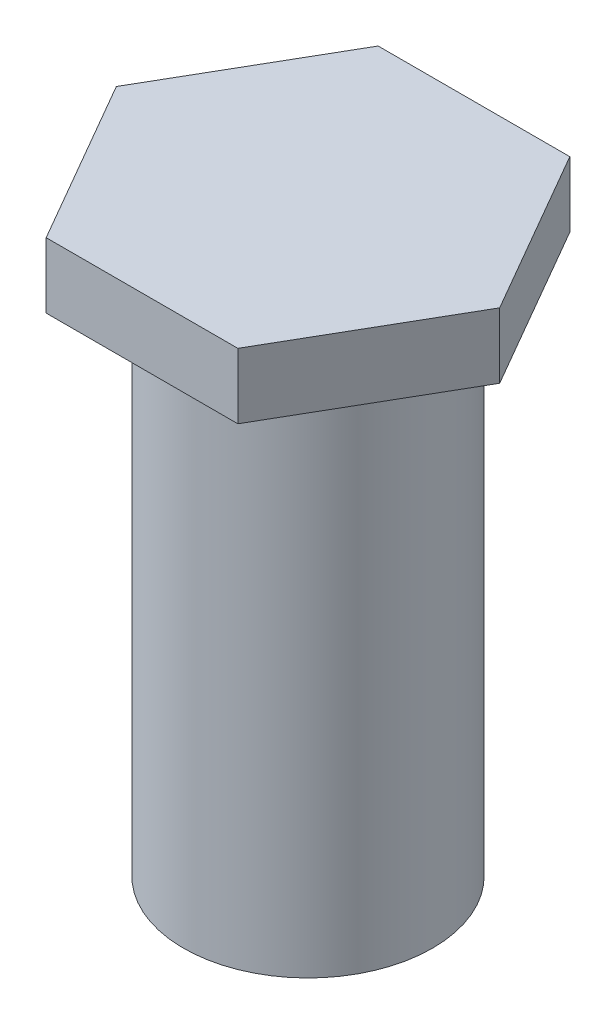
from build123d import *

# Parameters (mm, degrees)
CROQUIS1_W              = 4.765
CROQUIS1_H              = 20
SALIENTE_EXTRUIR1_DEPTH = 2.5


with BuildPart() as part:
    # Croquis1 → Revolución1 (revolve)
    with BuildSketch(Plane.XY):
        with Locations((2.3825, 10)):
            Rectangle(CROQUIS1_W, CROQUIS1_H)
    revolve(axis=Axis((0, 0, 0), (0, 1, 0)))

    # Croquis2 → Saliente-Extruir1 (add)
    with BuildSketch(Plane(origin=(0, 20, 0), x_dir=(1, 0, 0), z_dir=(0, 1, 0))):
        Polygon((-7.332348419, 0), (-3.666174209, -6.35), (3.666174209, -6.35), (7.332348419, 0), (3.666174209, 6.35), (-3.666174209, 6.35), align=None)
    extrude(amount=SALIENTE_EXTRUIR1_DEPTH)


solid = part.part
